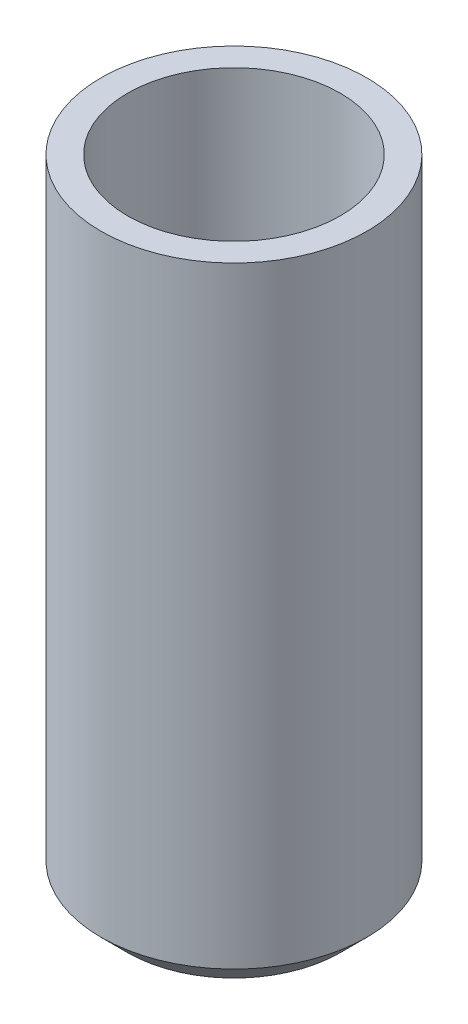
from build123d import *

# Parameters (mm, degrees)
SKETCH2_R          = 2
CUT_EXTRUDE1_DEPTH = 8


with BuildPart() as part:
    # Sketch1 → Revolve1 (revolve)
    with BuildSketch(Plane.XY):
        Polygon((0, 0), (2, 0), (2.5, 0.5), (2.5, 12), (0, 12), align=None)
    revolve(axis=Axis((0, 120.774509804, 0), (0, -1, 0)))

    # Sketch2 → Cut-Extrude1 (cut)
    with BuildSketch(Plane(origin=(0, 12, 0), x_dir=(1, 0, 0), z_dir=(0, 1, 0))):
        Circle(SKETCH2_R)
    extrude(amount=-CUT_EXTRUDE1_DEPTH, mode=Mode.SUBTRACT)


solid = part.part
